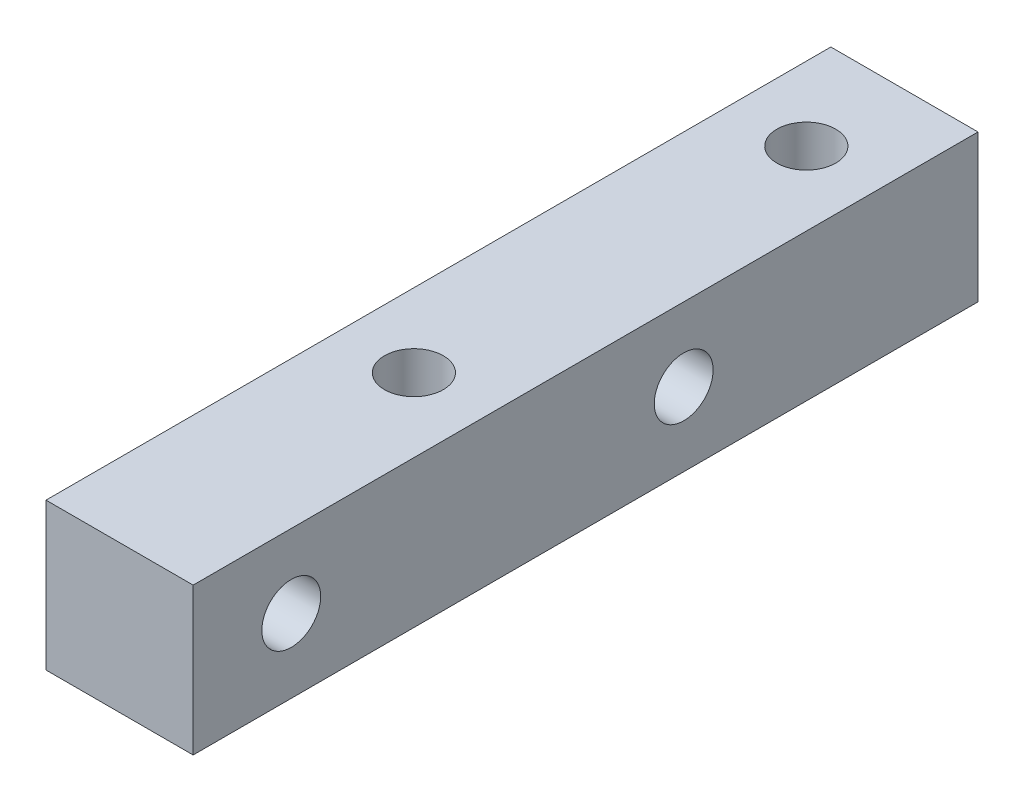
from build123d import *

# Parameters (mm, degrees)
SKETCH_1_W          = 6
SKETCH_1_H          = 6
EXTRUDE_1_DEPTH     = 32
SKETCH_2_R          = 1.2
CUT_EXTRUDE_1_DEPTH = 50
SKETCH_3_R          = 1.2
CUT_EXTRUDE_2_DEPTH = 50


with BuildPart() as part:
    # 草图1 → 凸台-拉伸1 (new body)
    with BuildSketch(Plane.XY):
        with Locations((3, 3)):
            Rectangle(SKETCH_1_W, SKETCH_1_H)
    extrude(amount=EXTRUDE_1_DEPTH)

    # 草图2 → 切除-拉伸1 (cut)
    with BuildSketch(Plane(origin=(0, 6, 0), x_dir=(1, 0, 0), z_dir=(0, 1, 0))):
        with Locations((3, -4)):
            Circle(SKETCH_2_R)
        with Locations((3, -20)):
            Circle(SKETCH_2_R)
    extrude(amount=-CUT_EXTRUDE_1_DEPTH, mode=Mode.SUBTRACT)

    # 草图3 → 切除-拉伸2 (cut)
    with BuildSketch(Plane.ZY):
        with Locations((28, 3)):
            Circle(SKETCH_3_R)
        with Locations((12, 3)):
            Circle(SKETCH_3_R)
    extrude(amount=-CUT_EXTRUDE_2_DEPTH, mode=Mode.SUBTRACT)


solid = part.part
